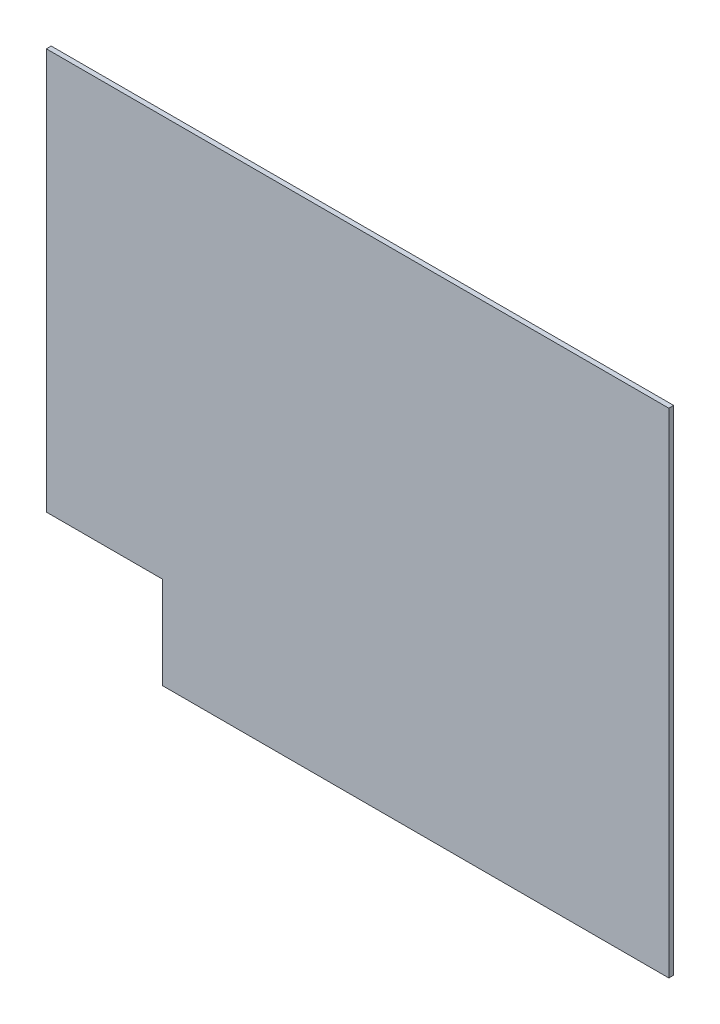
from build123d import *

# Parameters (mm, degrees)
SKETCH1_W           = 579
SKETCH1_H           = 459
BOSS_EXTRUDE1_DEPTH = 2.2479
SKETCH2_W           = 108.25
SKETCH2_H           = 85.8
CUT_EXTRUDE1_DEPTH  = 4.4958


with BuildPart() as part:
    # Sketch1 → Boss-Extrude1 (new body, symmetric)
    with BuildSketch(Plane.XY):
        Rectangle(SKETCH1_W, SKETCH1_H)
    extrude(amount=BOSS_EXTRUDE1_DEPTH, both=True)

    # Sketch2 → Cut-Extrude1 (cut)
    with BuildSketch(Plane(origin=(0, 0, -2.2479), x_dir=(-1, 0, 0), z_dir=(0, 0, -1))):
        with Locations((235.375, -186.6)):
            Rectangle(SKETCH2_W, SKETCH2_H)
    extrude(amount=-CUT_EXTRUDE1_DEPTH, mode=Mode.SUBTRACT)


solid = part.part
